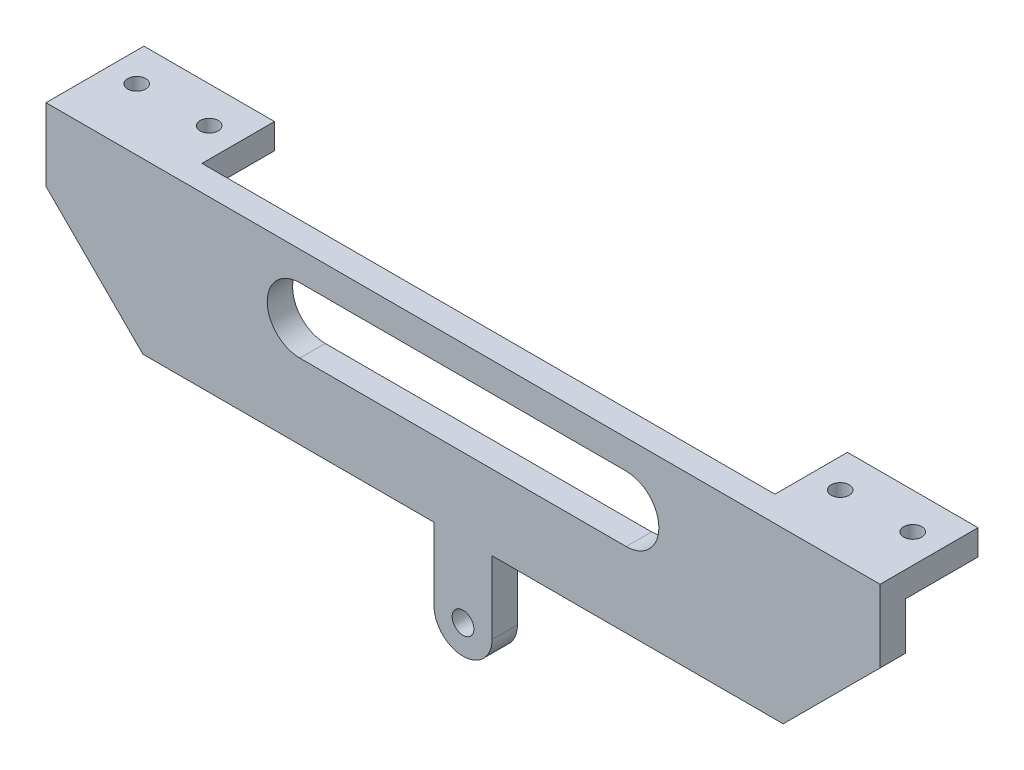
from build123d import *

# Parameters (mm, degrees)
SKETCH7_R           = 1.5
BOSS_EXTRUDE1_DEPTH = 3.5
SKETCH10_W          = 18
SKETCH10_H          = 10
SKETCH10_R          = 1.25
BOSS_EXTRUDE3_DEPTH = 3.5


with BuildPart() as part:
    # Sketch7 → Boss-Extrude1 (new body)
    with BuildSketch(Plane.XY):
        with BuildLine():
            Line((-4, 60), (-4, 70))
            Line((-4, 70), (-44.142135624, 70))
            Line((-44.142135624, 70), (-57.5, 83.35))
            Line((-57.5, 83.35), (-57.5, 93.35))
            Line((-57.5, 93.35), (57.5, 93.35))
            Line((57.5, 93.35), (57.5, 83.35))
            Line((57.5, 83.35), (44.142135624, 70))
            Line((44.142135624, 70), (4, 70))
            Line((4, 70), (4, 60))
            ThreePointArc((4, 60), (0, 56), (-4, 60))
        make_face()
        with Locations((0, 60)):
            Circle(SKETCH7_R, mode=Mode.SUBTRACT)
        with BuildLine():
            Line((22.5, 89.35), (-22.5, 89.35))
            ThreePointArc((-22.5, 89.35), (-27, 84.85), (-22.5, 80.35))
            Line((-22.5, 80.35), (22.5, 80.35))
            ThreePointArc((22.5, 80.35), (27, 84.85), (22.5, 89.35))
        make_face(mode=Mode.SUBTRACT)
    extrude(amount=BOSS_EXTRUDE1_DEPTH)

    # Sketch10 → Boss-Extrude3 (add)
    with BuildSketch(Plane(origin=(0, 93.35, 0), x_dir=(1, 0, 0), z_dir=(0, 1, 0))):
        with Locations((-48.5, 5)):
            Rectangle(SKETCH10_W, SKETCH10_H)
        with Locations((-53.5, 5)):
            Circle(SKETCH10_R, mode=Mode.SUBTRACT)
        with Locations((-43.5, 5)):
            Circle(SKETCH10_R, mode=Mode.SUBTRACT)
        with Locations((48.5, 5)):
            Rectangle(SKETCH10_W, SKETCH10_H)
        with Locations((43.5, 5)):
            Circle(SKETCH10_R, mode=Mode.SUBTRACT)
        with Locations((53.5, 5)):
            Circle(SKETCH10_R, mode=Mode.SUBTRACT)
    extrude(amount=-BOSS_EXTRUDE3_DEPTH)


solid = part.part
